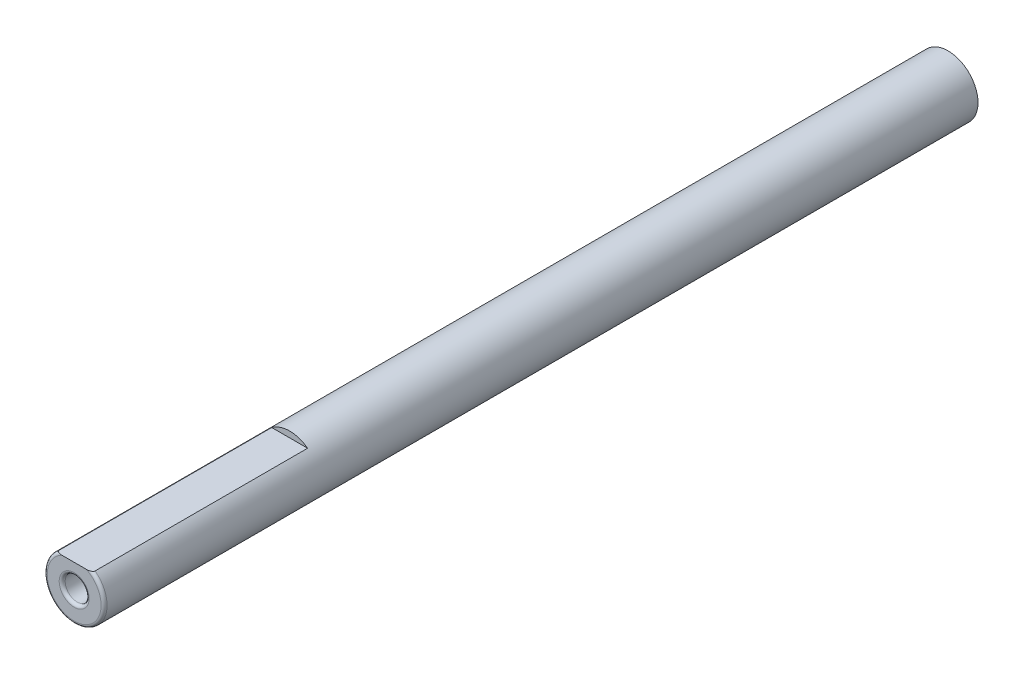
from build123d import *

# Parameters (mm, degrees)
SKETCH1_R          = 2.5
EXTRUDE1_DEPTH     = 73
SKETCH2_R          = 1
ICE1_DEPTH         = 10
FILLET1_R          = 0.25
CUT_EXTRUDE1_DEPTH = 18


with BuildPart() as part:
    # Sketch1 → Extrude1 (new body)
    with BuildSketch(Plane.XY):
        Circle(SKETCH1_R)
    extrude(amount=EXTRUDE1_DEPTH)

    # Sketch2 → ICE1 (cut)
    with BuildSketch(Plane.XY.offset(73)):
        Circle(SKETCH2_R)
    extrude(amount=-ICE1_DEPTH, mode=Mode.SUBTRACT)

    # Fillet1
    fillet1_edges = [part.edges().sort_by_distance(p)[0] for p in [
        (-2.5, 0, 73),
        (-1, 0, 73),
    ]]
    fillet(fillet1_edges, radius=FILLET1_R)

    # Sketch4 → Cut-Extrude1 (cut)
    with BuildSketch(Plane.XY.offset(73)):
        with BuildLine():
            Line((-1.5, 2), (1.5, 2))
            ThreePointArc((1.5, 2), (0, 2.5), (-1.5, 2))
        make_face()
    extrude(amount=-CUT_EXTRUDE1_DEPTH, mode=Mode.SUBTRACT)


solid = part.part
